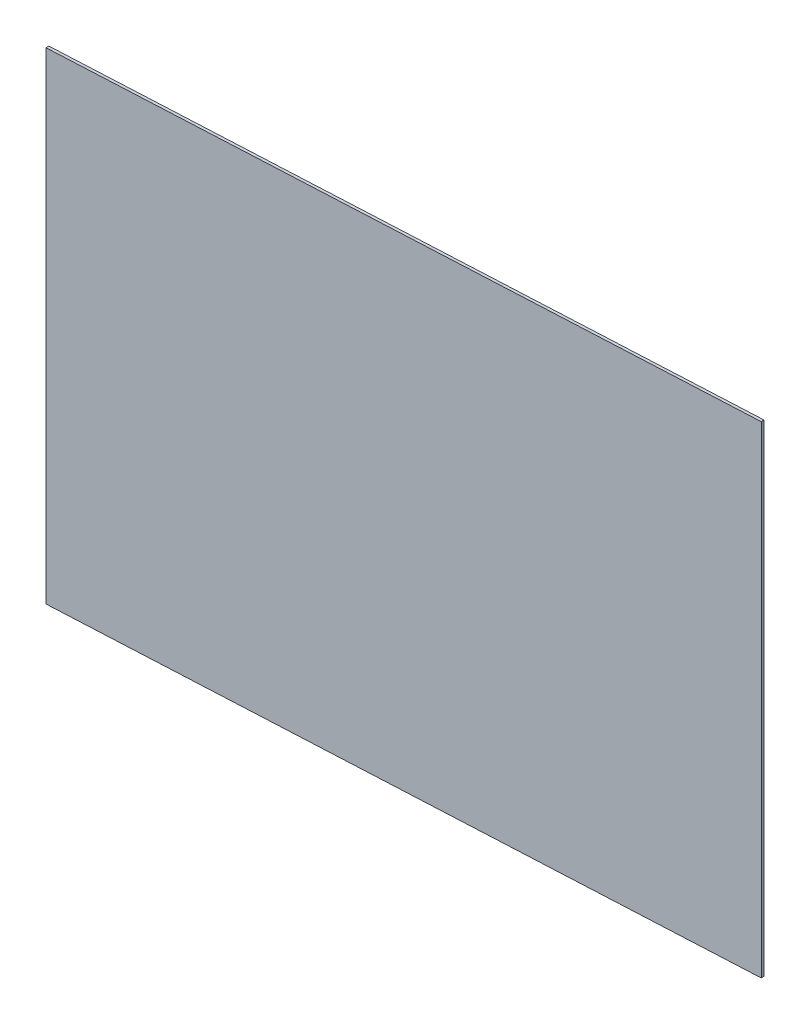
from build123d import *

# Parameters (mm, degrees)
SZKIC3_W                    = 553
SZKIC3_H                    = 390.5
DODANIE_WYCI_GNI_CIE1_DEPTH = 2.3


with BuildPart() as part:
    # Szkic3 → Dodanie-wyciągnięcie1 (new body)
    with BuildSketch(Plane(origin=(2.319661894, 0, 46.807463212), x_dir=(0.9987742832613944, 0, -0.049496778639502775), z_dir=(0.049496778639502775, 0, 0.9987742832613944))):
        with Locations((-1072.832082892, 0)):
            Rectangle(SZKIC3_W, SZKIC3_H)
    extrude(amount=DODANIE_WYCI_GNI_CIE1_DEPTH)


solid = part.part
